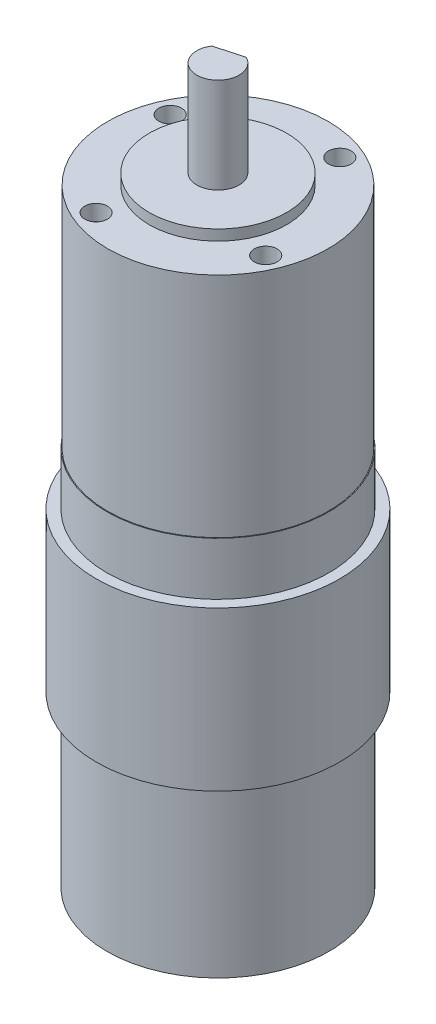
from build123d import *

# Parameters (mm, degrees)
SKETCH1_R           = 21
BOSS_EXTRUDE1_DEPTH = 72
SKETCH3_R           = 23
SKETCH3_R_2         = 21
BOSS_EXTRUDE2_DEPTH = 30
SKETCH4_R           = 20.85
BOSS_EXTRUDE3_DEPTH = 43
SKETCH5_R           = 13
BOSS_EXTRUDE4_DEPTH = 2
SKETCH6_R           = 4
BOSS_EXTRUDE5_DEPTH = 18
SKETCH8_R           = 7.5
BOSS_EXTRUDE6_DEPTH = 5
CIRPATTERN1_COUNT   = 4
CUT_EXTRUDE1_DEPTH  = 10


with BuildPart() as part:
    # Sketch1 → Boss-Extrude1 (new body)
    with BuildSketch(Plane(origin=(0, 0, 0), x_dir=(1, 0, 0), z_dir=(0, 1, 0))):
        Circle(SKETCH1_R)
    extrude(amount=BOSS_EXTRUDE1_DEPTH)

    # Sketch3 → Boss-Extrude2 (add)
    with BuildSketch(Plane(origin=(0, 62, 0), x_dir=(1, 0, 0), z_dir=(0, 1, 0))):
        Circle(SKETCH3_R)
        Circle(SKETCH3_R_2, mode=Mode.SUBTRACT)
    extrude(amount=-BOSS_EXTRUDE2_DEPTH)

    # Sketch4 → Boss-Extrude3 (add)
    with BuildSketch(Plane(origin=(0, 72, 0), x_dir=(1, 0, 0), z_dir=(0, 1, 0))):
        Circle(SKETCH4_R)
    extrude(amount=BOSS_EXTRUDE3_DEPTH)

    # Sketch5 → Boss-Extrude4 (add)
    with BuildSketch(Plane(origin=(0, 115, 0), x_dir=(1, 0, 0), z_dir=(0, 1, 0))):
        Circle(SKETCH5_R)
    extrude(amount=BOSS_EXTRUDE4_DEPTH)

    # Sketch6 → Boss-Extrude5 (add)
    with BuildSketch(Plane(origin=(0, 117, 0), x_dir=(1, 0, 0), z_dir=(0, 1, 0))):
        Circle(SKETCH6_R)
    extrude(amount=BOSS_EXTRUDE5_DEPTH)

    # Sketch8 → Boss-Extrude6 (add)
    with BuildSketch(Plane.XZ):
        Circle(SKETCH8_R)
    extrude(amount=BOSS_EXTRUDE6_DEPTH)

    # Sketch14 → CSK for M4 Flat Head Machine Screw1 (revolve, cut)
    with BuildSketch(Plane(origin=(-16.036289765, 117, -7.00624083), x_dir=(0, 0, 1), z_dir=(1, 0, 0))):
        Polygon((0, 0), (0, 6.291850331), (2.15, 5), (2.15, 0.6), (2.75, 0), align=None)
    csk_for_m4_flat_head_machine_screw1 = revolve(axis=Axis((-16.036289765, 123.35, -7.00624083), (0, -1, 0)), mode=Mode.SUBTRACT)

    # CirPattern1: CSK for M4 Flat Head Machine Screw1 ×4 about axis
    cirpattern1_axis = Axis((0, 0, 0), (0, 1, 0))
    for i in range(1, CIRPATTERN1_COUNT):
        add(csk_for_m4_flat_head_machine_screw1.rotate(cirpattern1_axis, i * 360 / CIRPATTERN1_COUNT), mode=Mode.SUBTRACT)

    # Sketch17 → Cut-Extrude1 (cut)
    with BuildSketch(Plane(origin=(0, 135, 0), x_dir=(1, 0, 0), z_dir=(0, 1, 0))):
        with BuildLine():
            Line((-3.345642255, 2.192413717), (1.757012768, 3.593453233))
            ThreePointArc((1.757012768, 3.593453233), (-1.059086325, 3.857244633), (-3.345642255, 2.192413717))
        make_face()
    extrude(amount=-CUT_EXTRUDE1_DEPTH, mode=Mode.SUBTRACT)


solid = part.part
